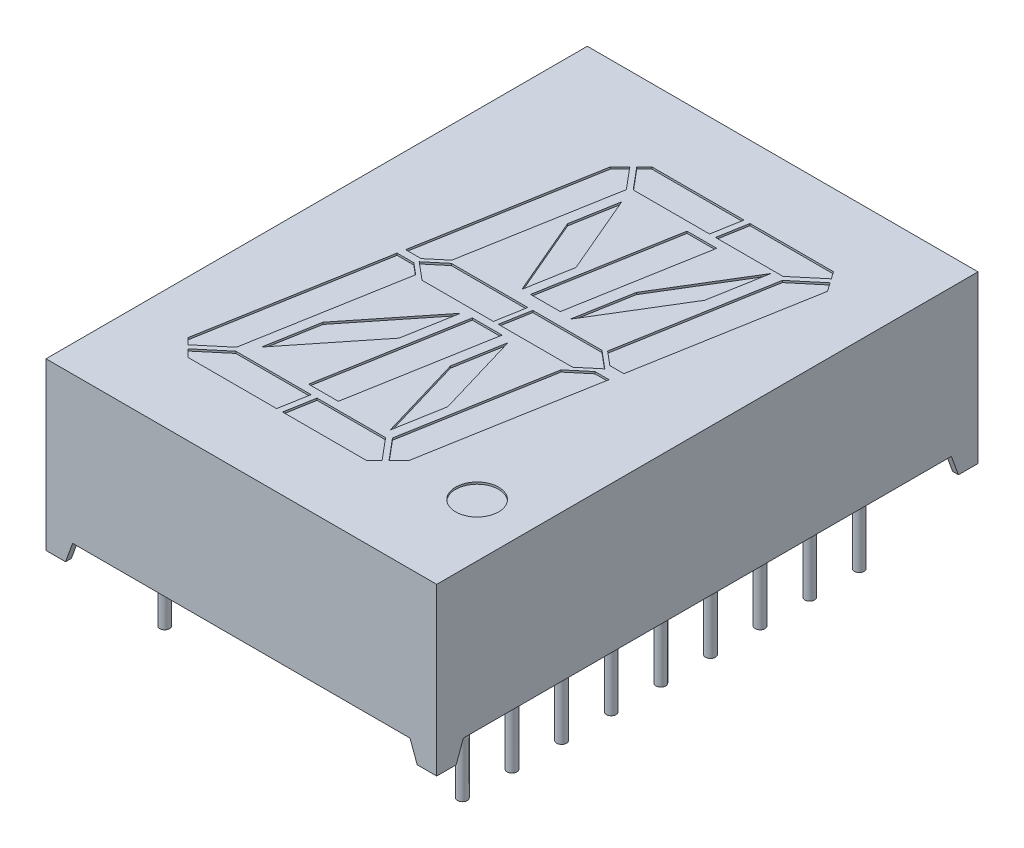
from build123d import *

# Parameters (mm, degrees)
SKETCH1_W          = 20
SKETCH1_H          = 27.71
EXTRUDE2_DEPTH     = 8.5
CUT_EXTRUDE2_DEPTH = 28.71
CUT_EXTRUDE3_DEPTH = 21
SKETCH6_R          = 1.1
CUT_EXTRUDE4_DEPTH = 0.1
SKETCH7_W          = 1.063970234
SKETCH7_H          = 1.063970234
CUT_EXTRUDE6_DEPTH = 1
SKETCH7_3_R        = 0.25
EXTRUDE3_DEPTH     = 1
SKETCH7_4_R        = 0.25
EXTRUDE4_DEPTH     = 4
SKETCH8_W          = 0.025316456
SKETCH8_H          = 0.026582278
CUT_EXTRUDE7_DEPTH = 0.01


with BuildPart() as part:
    # Sketch1 → Extrude2 (new body)
    with BuildSketch(Plane(origin=(0, 0, 0), x_dir=(1, 0, 0), z_dir=(0, 1, 0))):
        Rectangle(SKETCH1_W, SKETCH1_H)
    extrude(amount=-EXTRUDE2_DEPTH)

    # Sketch2 → Cut-Extrude2 (cut, through all)
    with BuildSketch(Plane.XY.offset(13.855)):
        Polygon((-9, -8.5), (-8.636029766, -7.5), (8.636029766, -7.5), (9, -8.5), align=None)
    extrude(amount=-CUT_EXTRUDE2_DEPTH, mode=Mode.SUBTRACT)

    # Sketch3 → Cut-Extrude3 (cut, through all)
    with BuildSketch(Plane(origin=(10, 0, 0), x_dir=(0, 0, -1), z_dir=(1, 0, 0))):
        Polygon((-12.855, -8.5), (-12.491029766, -7.5), (12.491029766, -7.5), (12.855, -8.5), align=None)
    extrude(amount=-CUT_EXTRUDE3_DEPTH, mode=Mode.SUBTRACT)

    # Sketch6 → Cut-Extrude4 (cut)
    with BuildSketch(Plane(origin=(0, 0, 0), x_dir=(-1, 0, 0), z_dir=(0, 1, 0))):
        Polygon((3.564962214, -9.596238766), (4.061861152, -9.099339828), (5.633410629, -0.186639852), (4.838716052, -0.186639852), (3.983777505, -0.904018471), (2.644523899, -8.499303098), align=None)
        Polygon((-1.716762292, -10.16), (3.00120098, -10.16), (3.387510261, -9.77369072), (2.453012788, -8.66), (-1.452271821, -8.66), align=None)
        Polygon((4.84221745, 0.183701829), (5.698711859, 0.183701829), (7.30194989, 9.276116524), (6.981177825, 9.596888588), (5.636403429, 8.468488889), (4.261493481, 0.670987097), align=None)
        Polygon((-6.295793119, -10.16), (-2.021390276, -10.16), (-1.756899805, -8.66), (-5.211216056, -8.66), (-6.555990451, -9.788399699), align=None)
        Polygon((3.856184806, -0.75), (4.75, 0), (3.856184806, 0.75), (0.205292288, 0.75), (-0.059198183, -0.75), align=None)
        Polygon((5.475706527, 8.66), (6.803725871, 9.774340542), (6.418066413, 10.16), (1.888384149, 10.16), (1.623893678, 8.66), align=None)
        Polygon((-7.012763665, -9.136059945), (-6.699932303, -9.582829431), (-5.371912958, -8.468488889), (-4.031092235, -0.864316698), (-4.733554655, -0.274880741), (-5.45029869, -0.274880741), align=None)
        Polygon((-3.856184806, -0.75), (-0.313054836, -0.75), (-0.048564365, 0.75), (-3.856184806, 0.75), (-4.75, 0), align=None)
        Polygon((-2.188522317, 8.66), (1.319265694, 8.66), (1.583756165, 10.16), (-2.736710509, 10.16), (-3.123019789, 9.77369072), align=None)
        Polygon((-3.797370681, 9.099339828), (-5.336480587, 0.370613801), (-4.619464437, 0.370613801), (-3.673358746, 1.164490737), (-2.380033428, 8.499303098), (-3.300471743, 9.596238766), align=None)
        Polygon((-2.27297919, -8.210157035), (-0.749839272, -8.210157035), (0.450916268, -1.40033397), (-1.07222365, -1.40033397), align=None)
        Polygon((-0.625673028, 1.132180455), (0.89746689, 1.132180455), (2.154174684, 8.25932452), (0.631034766, 8.25932452), align=None)
        Polygon((1.407680367, 1.228827124), (4.531194855, 5.145212023), (5.002967697, 7.820768764), (1.879453208, 3.904383864), align=None)
        Polygon((-2.409232885, 5.69968464), (-1.112825589, 1.314182511), (-0.67100747, 3.819857575), (-1.967414766, 8.205359704), align=None)
        Polygon((-2.167540747, -4.194861436), (-1.659236888, -1.312127006), (-4.267446218, -5.599560209), (-4.775750076, -8.48229464), align=None)
        Polygon((0.482024646, -3.756424015), (2.222968776, -7.839914095), (2.63841102, -5.48382405), (0.89746689, -1.40033397), align=None)
        with Locations(Location((-7.273660374, 9.06, 0), (0, 0, 90))):  # turned: the seam where the file's is
            Circle(SKETCH6_R)
    extrude(amount=-CUT_EXTRUDE4_DEPTH, mode=Mode.SUBTRACT)

    # Sketch7 → Cut-Extrude6 (cut)
    with BuildSketch(Plane.XZ.offset(8.5)):
        with Locations((-9.168014883, 13.023014883)):
            Rectangle(SKETCH7_W, SKETCH7_H)
        with Locations((-9.168014883, -13.023014883)):
            Rectangle(SKETCH7_W, SKETCH7_H)
        with Locations((9.168014883, -13.023014883)):
            Rectangle(SKETCH7_W, SKETCH7_H)
        with Locations((9.168014883, 13.023014883)):
            Rectangle(SKETCH7_W, SKETCH7_H)
    extrude(amount=-CUT_EXTRUDE6_DEPTH, mode=Mode.SUBTRACT)

    # Sketch7_3 → Extrude3 (add)
    with BuildSketch(Plane.XZ.offset(8.5)):
        with Locations(Location((-7.62, 10.16, 0), (0, 0, 270))):  # turned: the seam where the file's is
            Circle(SKETCH7_3_R)
        with Locations(Location((-7.62, 7.62, 0), (0, 0, 270))):  # turned: the seam where the file's is
            Circle(SKETCH7_3_R)
        with Locations(Location((-7.62, 5.08, 0), (0, 0, 270))):  # turned: the seam where the file's is
            Circle(SKETCH7_3_R)
        with Locations(Location((-7.62, 2.54, 0), (0, 0, 270))):  # turned: the seam where the file's is
            Circle(SKETCH7_3_R)
        with Locations(Location((-7.62, 0, 0), (0, 0, 270))):  # turned: the seam where the file's is
            Circle(SKETCH7_3_R)
        with Locations(Location((-7.62, -2.54, 0), (0, 0, 270))):  # turned: the seam where the file's is
            Circle(SKETCH7_3_R)
        with Locations(Location((-7.62, -5.08, 0), (0, 0, 270))):  # turned: the seam where the file's is
            Circle(SKETCH7_3_R)
        with Locations(Location((-7.62, -7.62, 0), (0, 0, 270))):  # turned: the seam where the file's is
            Circle(SKETCH7_3_R)
        with Locations(Location((-7.62, -10.16, 0), (0, 0, 270))):  # turned: the seam where the file's is
            Circle(SKETCH7_3_R)
        with Locations(Location((7.62, -10.16, 0), (0, 0, 270))):  # turned: the seam where the file's is
            Circle(SKETCH7_3_R)
        with Locations(Location((7.62, -7.62, 0), (0, 0, 270))):  # turned: the seam where the file's is
            Circle(SKETCH7_3_R)
        with Locations(Location((7.62, -5.08, 0), (0, 0, 270))):  # turned: the seam where the file's is
            Circle(SKETCH7_3_R)
        with Locations(Location((7.62, -2.54, 0), (0, 0, 270))):  # turned: the seam where the file's is
            Circle(SKETCH7_3_R)
        with Locations(Location((7.62, 0, 0), (0, 0, 270))):  # turned: the seam where the file's is
            Circle(SKETCH7_3_R)
        with Locations(Location((7.62, 2.54, 0), (0, 0, 270))):  # turned: the seam where the file's is
            Circle(SKETCH7_3_R)
        with Locations(Location((7.62, 5.08, 0), (0, 0, 270))):  # turned: the seam where the file's is
            Circle(SKETCH7_3_R)
        with Locations(Location((7.62, 7.62, 0), (0, 0, 270))):  # turned: the seam where the file's is
            Circle(SKETCH7_3_R)
        with Locations(Location((7.62, 10.16, 0), (0, 0, 270))):  # turned: the seam where the file's is
            Circle(SKETCH7_3_R)
    extrude(amount=-EXTRUDE3_DEPTH)

    # Sketch7_4 → Extrude4 (add)
    with BuildSketch(Plane.XZ.offset(8.5)):
        with Locations(Location((-7.62, 10.16, 0), (0, 0, 270))):  # turned: the seam where the file's is
            Circle(SKETCH7_4_R)
        with Locations(Location((-7.62, 7.62, 0), (0, 0, 270))):  # turned: the seam where the file's is
            Circle(SKETCH7_4_R)
        with Locations(Location((-7.62, 5.08, 0), (0, 0, 270))):  # turned: the seam where the file's is
            Circle(SKETCH7_4_R)
        with Locations(Location((-7.62, 2.54, 0), (0, 0, 270))):  # turned: the seam where the file's is
            Circle(SKETCH7_4_R)
        with Locations(Location((-7.62, 0, 0), (0, 0, 270))):  # turned: the seam where the file's is
            Circle(SKETCH7_4_R)
        with Locations(Location((-7.62, -2.54, 0), (0, 0, 270))):  # turned: the seam where the file's is
            Circle(SKETCH7_4_R)
        with Locations(Location((-7.62, -5.08, 0), (0, 0, 270))):  # turned: the seam where the file's is
            Circle(SKETCH7_4_R)
        with Locations(Location((-7.62, -7.62, 0), (0, 0, 270))):  # turned: the seam where the file's is
            Circle(SKETCH7_4_R)
        with Locations(Location((-7.62, -10.16, 0), (0, 0, 270))):  # turned: the seam where the file's is
            Circle(SKETCH7_4_R)
        with Locations(Location((7.62, -10.16, 0), (0, 0, 270))):  # turned: the seam where the file's is
            Circle(SKETCH7_4_R)
        with Locations(Location((7.62, -7.62, 0), (0, 0, 270))):  # turned: the seam where the file's is
            Circle(SKETCH7_4_R)
        with Locations(Location((7.62, -5.08, 0), (0, 0, 270))):  # turned: the seam where the file's is
            Circle(SKETCH7_4_R)
        with Locations(Location((7.62, -2.54, 0), (0, 0, 270))):  # turned: the seam where the file's is
            Circle(SKETCH7_4_R)
        with Locations(Location((7.62, 0, 0), (0, 0, 270))):  # turned: the seam where the file's is
            Circle(SKETCH7_4_R)
        with Locations(Location((7.62, 2.54, 0), (0, 0, 270))):  # turned: the seam where the file's is
            Circle(SKETCH7_4_R)
        with Locations(Location((7.62, 5.08, 0), (0, 0, 270))):  # turned: the seam where the file's is
            Circle(SKETCH7_4_R)
        with Locations(Location((7.62, 7.62, 0), (0, 0, 270))):  # turned: the seam where the file's is
            Circle(SKETCH7_4_R)
        with Locations(Location((7.62, 10.16, 0), (0, 0, 270))):  # turned: the seam where the file's is
            Circle(SKETCH7_4_R)
    extrude(amount=EXTRUDE4_DEPTH)

    # Sketch8 → Cut-Extrude7 (cut)
    with BuildSketch(Plane.XZ.offset(7.5)):
        Polygon((0.977729481, 10.289242078), (1.00118676, 10.363925622), (1.02592964, 10.363925622), (1.042345779, 10.313589388), (1.057871886, 10.363925622), (1.08360369, 10.363925622), (1.106843405, 10.289242078), (1.081665399, 10.289242078), (1.068670937, 10.340725464), (1.052254798, 10.289242078), (1.030755589, 10.289242078), (1.014438342, 10.340725464), (1.001621886, 10.289242078), align=None)
        Polygon((0.843552266, 10.289242078), (0.867009545, 10.363925622), (0.891752424, 10.363925622), (0.908168564, 10.313589388), (0.923694671, 10.363925622), (0.949426475, 10.363925622), (0.97266619, 10.289242078), (0.947488184, 10.289242078), (0.934493722, 10.340725464), (0.918077583, 10.289242078), (0.896578374, 10.289242078), (0.880261127, 10.340725464), (0.867444671, 10.289242078), align=None)
        Polygon((0.709375051, 10.289242078), (0.73283233, 10.363925622), (0.757575209, 10.363925622), (0.773991349, 10.313589388), (0.789517456, 10.363925622), (0.81524926, 10.363925622), (0.838488975, 10.289242078), (0.813310969, 10.289242078), (0.800316507, 10.340725464), (0.783900368, 10.289242078), (0.762401159, 10.289242078), (0.746083912, 10.340725464), (0.733267456, 10.289242078), align=None)
        with Locations((0.68152695, 10.350634483)):
            Rectangle(SKETCH8_W, SKETCH8_H)
        with BuildLine():
            add(Edge.make_bspline(
                [(0.565071254, 10.332754736), (0.565107782, 10.33397685), (0.565179511, 10.336376675), (0.565788673, 10.339884641), (0.566784197, 10.343207924), (0.568148535, 10.346370639), (0.569962523, 10.349326005), (0.572117537, 10.352144573), (0.574729451, 10.354728534), (0.577666487, 10.357167296), (0.580964415, 10.35934969), (0.584567036, 10.361249829), (0.588437356, 10.362874547), (0.592591377, 10.364206237), (0.597036955, 10.365197004), (0.601754731, 10.365920321), (0.60674808, 10.366393829), (0.610171668, 10.36643577), (0.611926475, 10.366457268)],
                knots=[0, 0, 0, 0, 0.907421153, 1.781872267, 2.635683434, 3.480115191, 4.332689235, 5.205575272, 6.109500117, 7.055808355, 8.037942167, 9.041423561, 10.07750834, 11.152467461, 12.277657752, 13.45734338, 14.696726425, 16, 16, 16, 16], degree=3))
            add(Edge.make_bspline(
                [(0.611926475, 10.366457268), (0.61394446, 10.366430003), (0.617852646, 10.366377199), (0.623520214, 10.365991826), (0.62878368, 10.365303877), (0.633681427, 10.364347296), (0.638285728, 10.363144011), (0.642719072, 10.361853367), (0.647000365, 10.360388787), (0.649773457, 10.35928865), (0.651147203, 10.35874366)],
                knots=[0, 0, 0, 0, 1.203182053, 2.33017619, 3.384818652, 4.366208123, 5.30340534, 6.221361684, 7.118890722, 8, 8, 8, 8], degree=3))
            Line((0.651147203, 10.35874366), (0.651147203, 10.334811698))
            Line((0.651147203, 10.334811698), (0.648299102, 10.334811698))
            add(Edge.make_bspline(
                [(0.648299102, 10.334811698), (0.646933538, 10.335892661), (0.644210429, 10.33804824), (0.639783471, 10.340816594), (0.635124459, 10.343189605), (0.630286065, 10.345172227), (0.625384697, 10.346747842), (0.620515629, 10.347874747), (0.615746646, 10.348614112), (0.612588325, 10.348695673), (0.611036443, 10.348735749)],
                knots=[0, 0, 0, 0, 1.030738938, 2.055426519, 3.085610749, 4.123842265, 5.148648843, 6.130724483, 7.081507926, 8, 8, 8, 8], degree=3))
            add(Edge.make_bspline(
                [(0.611036443, 10.348735749), (0.610607697, 10.348734448), (0.609689785, 10.348731664), (0.608220637, 10.348610349), (0.606564293, 10.348482504), (0.604783555, 10.34828639), (0.60299635, 10.348055246), (0.601336103, 10.347708778), (0.599835341, 10.347339627), (0.598928672, 10.346972361), (0.598496886, 10.346797458)],
                knots=[0, 0, 0, 0, 0.806537132, 1.726733348, 2.77251655, 3.932999672, 5.098049949, 6.161349231, 7.124375527, 8, 8, 8, 8], degree=3))
            add(Edge.make_bspline(
                [(0.598496886, 10.346797458), (0.5980174, 10.346569222), (0.597075108, 10.346120691), (0.595772577, 10.345306781), (0.594602092, 10.344412036), (0.59354139, 10.343450303), (0.592678994, 10.342287314), (0.592057833, 10.340888043), (0.591713263, 10.339238751), (0.591674191, 10.338063589), (0.591653532, 10.337442236)],
                knots=[0, 0, 0, 0, 1.02474257, 2.013837243, 2.958431669, 3.867978675, 4.769292696, 5.732237074, 6.800947934, 8, 8, 8, 8], degree=3))
            add(Edge.make_bspline(
                [(0.591653532, 10.337442236), (0.591684993, 10.33689637), (0.591746856, 10.335823036), (0.592328362, 10.334294607), (0.593212408, 10.332874471), (0.594491824, 10.331609134), (0.596105502, 10.330483022), (0.598036489, 10.329472259), (0.60031034, 10.328636502), (0.601947553, 10.328198629), (0.602808595, 10.327968344)],
                knots=[0, 0, 0, 0, 0.825427492, 1.623033598, 2.45033906, 3.348940377, 4.33183287, 5.428402891, 6.647546779, 8, 8, 8, 8], degree=3))
            add(Edge.make_bspline(
                [(0.602808595, 10.327968344), (0.604777836, 10.327523139), (0.608813048, 10.326610861), (0.614952861, 10.325423407), (0.621091563, 10.324197536), (0.62504782, 10.322983221), (0.626977899, 10.322390812)],
                knots=[0, 0, 0, 0, 0.976118991, 2.000185432, 3.024380873, 4, 4, 4, 4], degree=3))
            add(Edge.make_bspline(
                [(0.626977899, 10.322390812), (0.628016052, 10.322037089), (0.630036914, 10.321348535), (0.632936106, 10.320195887), (0.635579353, 10.318890752), (0.638036893, 10.317568714), (0.640229556, 10.316088657), (0.64222419, 10.314555897), (0.643976851, 10.312903093), (0.645503289, 10.3111536), (0.646846155, 10.309317239), (0.647999564, 10.307370097), (0.648960587, 10.305303648), (0.649783979, 10.30314825), (0.650395205, 10.300873715), (0.650817642, 10.298497298), (0.651115705, 10.296013812), (0.651136561, 10.294319476), (0.651147203, 10.293454894)],
                knots=[0, 0, 0, 0, 1.287376879, 2.505999703, 3.65855109, 4.746193839, 5.778582289, 6.760029101, 7.696159662, 8.601061861, 9.48181646, 10.363080883, 11.252765705, 12.153987336, 13.068239035, 14.012364187, 14.985753787, 16, 16, 16, 16], degree=3))
            add(Edge.make_bspline(
                [(0.651147203, 10.293454894), (0.651109903, 10.292298748), (0.651036496, 10.290023473), (0.650435046, 10.286694451), (0.649408535, 10.283545632), (0.648022176, 10.280542476), (0.646194683, 10.277728213), (0.64400256, 10.275050726), (0.64139225, 10.27255823), (0.638406923, 10.270259594), (0.635120075, 10.268180788), (0.63158607, 10.266344081), (0.627807219, 10.264837633), (0.623827334, 10.263556402), (0.619607941, 10.262604007), (0.615170971, 10.261884429), (0.610497108, 10.261471428), (0.607305697, 10.261420153), (0.605676475, 10.261393977)],
                knots=[0, 0, 0, 0, 0.894901293, 1.761149761, 2.608783409, 3.453876344, 4.314933854, 5.200038827, 6.12799933, 7.103249695, 8.113098521, 9.136064399, 10.182719798, 11.259667356, 12.370545059, 13.528828137, 14.738461593, 16, 16, 16, 16], degree=3))
            add(Edge.make_bspline(
                [(0.605676475, 10.261393977), (0.604007823, 10.261416369), (0.60067335, 10.261461117), (0.595691377, 10.261836087), (0.590733962, 10.262402588), (0.585862398, 10.263202042), (0.581179891, 10.264219698), (0.576763277, 10.265305656), (0.572684307, 10.266546046), (0.570110582, 10.267500091), (0.568868722, 10.267960432)],
                knots=[0, 0, 0, 0, 1.065379838, 2.128953261, 3.188461447, 4.250817766, 5.279613205, 6.247547721, 7.154416075, 8, 8, 8, 8], degree=3))
            Line((0.568868722, 10.267960432), (0.568868722, 10.290507901))
            Line((0.568868722, 10.290507901), (0.571697045, 10.290507901))
            add(Edge.make_bspline(
                [(0.571697045, 10.290507901), (0.572770004, 10.289707697), (0.574964235, 10.288071259), (0.578622987, 10.285985282), (0.582587048, 10.284035768), (0.586851949, 10.282313975), (0.59132449, 10.280893375), (0.595902036, 10.27986433), (0.600529101, 10.279225207), (0.603630692, 10.279152074), (0.605182013, 10.279115496)],
                knots=[0, 0, 0, 0, 0.89224925, 1.824673196, 2.804309561, 3.838364047, 4.890042674, 5.931526337, 6.965412421, 8, 8, 8, 8], degree=3))
            add(Edge.make_bspline(
                [(0.605182013, 10.279115496), (0.606277313, 10.279139706), (0.608467058, 10.279188106), (0.611741466, 10.27953736), (0.614976257, 10.280209102), (0.617019156, 10.281023438), (0.618038026, 10.281429578)],
                knots=[0, 0, 0, 0, 0.998993879, 1.997209027, 3.00113285, 4, 4, 4, 4], degree=3))
            add(Edge.make_bspline(
                [(0.618038026, 10.281429578), (0.618471505, 10.281631061), (0.619338174, 10.282033892), (0.620545178, 10.282806218), (0.621648481, 10.283735935), (0.622649487, 10.284788329), (0.623497543, 10.285957664), (0.624135203, 10.287227424), (0.624496022, 10.288589402), (0.624541859, 10.289523571), (0.624564924, 10.28999366)],
                knots=[0, 0, 0, 0, 1.005454979, 2.010239304, 3.005296729, 4.036100111, 5.060531193, 6.034954812, 7.011155677, 8, 8, 8, 8], degree=3))
            add(Edge.make_bspline(
                [(0.624564924, 10.28999366), (0.62453013, 10.290631591), (0.624463641, 10.291850619), (0.623863644, 10.293564316), (0.622865975, 10.295027427), (0.621712876, 10.296020421), (0.620595897, 10.29671918), (0.61955538, 10.29722442), (0.618355929, 10.297737843), (0.61697848, 10.29822704), (0.615443345, 10.298721087), (0.613734422, 10.299195756), (0.611851815, 10.299645316), (0.610535924, 10.299931468), (0.609849735, 10.300080686)],
                knots=[0, 0, 0, 0, 1.174343879, 2.244064321, 3.303704314, 4.407076671, 5.02483983, 5.732197225, 6.53898402, 7.431906431, 8.428480183, 9.514816237, 10.704066255, 12, 12, 12, 12], degree=3))
            add(Edge.make_bspline(
                [(0.609849735, 10.300080686), (0.60801711, 10.300457406), (0.604416407, 10.301197578), (0.599011332, 10.302291874), (0.593518278, 10.303604392), (0.589847728, 10.304733604), (0.587935178, 10.305321983)],
                knots=[0, 0, 0, 0, 0.995788186, 1.956503735, 2.935230479, 4, 4, 4, 4], degree=3))
            add(Edge.make_bspline(
                [(0.587935178, 10.305321983), (0.586988621, 10.305641224), (0.585137004, 10.306265712), (0.582496406, 10.307352031), (0.580049232, 10.308525888), (0.577782598, 10.309767857), (0.575707233, 10.31111029), (0.573820943, 10.312535624), (0.572122986, 10.314040406), (0.570634237, 10.315656126), (0.56930548, 10.317366474), (0.568193136, 10.319217087), (0.56719755, 10.321160616), (0.566444396, 10.32325406), (0.565819886, 10.325452587), (0.565398144, 10.327784522), (0.565103781, 10.330228739), (0.565082217, 10.331903339), (0.565071254, 10.332754736)],
                knots=[0, 0, 0, 0, 1.237326419, 2.420410185, 3.534642089, 4.598489486, 5.620241961, 6.59385002, 7.525152549, 8.426792174, 9.312230456, 10.203151844, 11.098070343, 12.012931196, 12.954244379, 13.926618287, 14.945853925, 16, 16, 16, 16], degree=3))
        make_face()
        with BuildLine():
            Line((0.47266619, 10.363925622), (0.496716823, 10.363925622))
            Line((0.496716823, 10.363925622), (0.496716823, 10.356093344))
            add(Edge.make_bspline(
                [(0.496716823, 10.356093344), (0.497810017, 10.356902139), (0.499917679, 10.358461483), (0.503092238, 10.360538545), (0.506110538, 10.362322967), (0.50904089, 10.363846085), (0.512047167, 10.365058255), (0.515285301, 10.365876636), (0.518786897, 10.36637936), (0.521213967, 10.366430721), (0.522468405, 10.366457268)],
                knots=[0, 0, 0, 0, 1.150945962, 2.219006967, 3.209666795, 4.118194914, 5.012574058, 5.946577101, 6.93868214, 8, 8, 8, 8], degree=3))
            add(Edge.make_bspline(
                [(0.522468405, 10.366457268), (0.52348468, 10.36643432), (0.525463661, 10.366389634), (0.528341961, 10.366047913), (0.531043927, 10.365499504), (0.533572764, 10.364731098), (0.535922464, 10.363728067), (0.538066144, 10.362456432), (0.540068721, 10.361023718), (0.541850668, 10.359317353), (0.543466214, 10.357419434), (0.544848785, 10.355287025), (0.54602649, 10.352954086), (0.54696759, 10.350402236), (0.547722678, 10.347643931), (0.548246611, 10.344664684), (0.548567203, 10.341477556), (0.548599143, 10.339282426), (0.548615557, 10.338154262)],
                knots=[0, 0, 0, 0, 1.108959949, 2.159465255, 3.158589008, 4.114545495, 5.039534357, 5.93921201, 6.830099133, 7.720870013, 8.624681761, 9.544731627, 10.487599671, 11.471264588, 12.508152322, 13.604835107, 14.769030043, 16, 16, 16, 16], degree=3))
            Line((0.548615557, 10.338154262), (0.548615557, 10.289242078))
            Line((0.548615557, 10.289242078), (0.524564924, 10.289242078))
            Line((0.524564924, 10.289242078), (0.524564924, 10.326821192))
            add(Edge.make_bspline(
                [(0.524564924, 10.326821192), (0.524563289, 10.327737663), (0.524560158, 10.329491879), (0.52447782, 10.331997685), (0.524356919, 10.334265858), (0.524218214, 10.336307886), (0.523965198, 10.338154637), (0.523587489, 10.339820798), (0.523116663, 10.3413404), (0.522652344, 10.342247101), (0.522428849, 10.342683534)],
                knots=[0, 0, 0, 0, 1.361401701, 2.605856924, 3.723918663, 4.735739235, 5.645738665, 6.489217889, 7.27279937, 8, 8, 8, 8], degree=3))
            add(Edge.make_bspline(
                [(0.522428849, 10.342683534), (0.52219884, 10.343082239), (0.521746663, 10.343866061), (0.520826399, 10.344872372), (0.519747556, 10.345716122), (0.518470353, 10.346374223), (0.516980786, 10.346864726), (0.515259927, 10.347245297), (0.513268185, 10.347417175), (0.511860717, 10.347451666), (0.511115557, 10.347469926)],
                knots=[0, 0, 0, 0, 0.849004071, 1.669068917, 2.503060811, 3.370079215, 4.310762265, 5.396376419, 6.621555549, 8, 8, 8, 8], degree=3))
            add(Edge.make_bspline(
                [(0.511115557, 10.347469926), (0.510574615, 10.347450087), (0.509463198, 10.347409326), (0.507745746, 10.347217785), (0.505956486, 10.346818626), (0.503437817, 10.346173681), (0.500272607, 10.344979827), (0.497913073, 10.34362668), (0.496716823, 10.342940654)],
                knots=[0, 0, 0, 0, 0.638062719, 1.310959128, 2.033463623, 2.796942592, 4.376095945, 6, 6, 6, 6], degree=3))
            Line((0.496716823, 10.342940654), (0.496716823, 10.289242078))
            Line((0.496716823, 10.289242078), (0.47266619, 10.289242078))
            Line((0.47266619, 10.289242078), (0.47266619, 10.363925622))
        make_face()
        with BuildLine():
            Line((0.375197836, 10.363925622), (0.399248469, 10.363925622))
            Line((0.399248469, 10.363925622), (0.399248469, 10.326346508))
            add(Edge.make_bspline(
                [(0.399248469, 10.326346508), (0.399273475, 10.324816519), (0.399323447, 10.321759028), (0.399599998, 10.317995933), (0.399984484, 10.315154394), (0.400352024, 10.313322805), (0.400783895, 10.311774689), (0.401196157, 10.310888927), (0.401384545, 10.310484167)],
                knots=[0, 0, 0, 0, 1.709111167, 3.415443484, 4.21113913, 4.910175115, 5.501990373, 6, 6, 6, 6], degree=3))
            add(Edge.make_bspline(
                [(0.401384545, 10.310484167), (0.401629006, 10.310086104), (0.402108305, 10.309305645), (0.403045656, 10.308292769), (0.40413944, 10.307463401), (0.405410616, 10.306783933), (0.406898725, 10.306304746), (0.408622642, 10.305951991), (0.410602827, 10.305741438), (0.412011655, 10.305712884), (0.412757171, 10.305697774)],
                knots=[0, 0, 0, 0, 0.860202684, 1.686548532, 2.528236983, 3.382486038, 4.33249885, 5.401154041, 6.624757403, 8, 8, 8, 8], degree=3))
            add(Edge.make_bspline(
                [(0.412757171, 10.305697774), (0.41388806, 10.305757875), (0.416195756, 10.305880516), (0.419071066, 10.306547182), (0.421388404, 10.307407147), (0.42324612, 10.308157582), (0.425153842, 10.309131683), (0.426433385, 10.309853124), (0.42709657, 10.310227046)],
                knots=[0, 0, 0, 0, 1.33818541, 2.730705359, 3.468371228, 4.262126284, 5.099261778, 6, 6, 6, 6], degree=3))
            Line((0.42709657, 10.310227046), (0.42709657, 10.363925622))
            Line((0.42709657, 10.363925622), (0.451147203, 10.363925622))
            Line((0.451147203, 10.363925622), (0.451147203, 10.289242078))
            Line((0.451147203, 10.289242078), (0.42709657, 10.289242078))
            Line((0.42709657, 10.289242078), (0.42709657, 10.297074356))
            add(Edge.make_bspline(
                [(0.42709657, 10.297074356), (0.426039163, 10.296268205), (0.423980859, 10.294698983), (0.420801621, 10.292658562), (0.417717723, 10.290859793), (0.414664713, 10.289346976), (0.411549758, 10.288140202), (0.408287, 10.287329213), (0.404870594, 10.28678541), (0.402533879, 10.286735716), (0.401344988, 10.286710432)],
                knots=[0, 0, 0, 0, 1.126119141, 2.192057864, 3.198061997, 4.149848529, 5.076251285, 6.021887753, 6.99356175, 8, 8, 8, 8], degree=3))
            add(Edge.make_bspline(
                [(0.401344988, 10.286710432), (0.400348723, 10.286735833), (0.398403836, 10.286785419), (0.395568987, 10.287094971), (0.39289788, 10.287646194), (0.390404496, 10.28844205), (0.38806881, 10.289433409), (0.385895138, 10.290637389), (0.383909289, 10.29210067), (0.382081137, 10.293760609), (0.380442037, 10.295651906), (0.379045127, 10.297781284), (0.377840765, 10.300118205), (0.3768915, 10.302680842), (0.376100176, 10.305447114), (0.375595412, 10.308445743), (0.375237759, 10.311655629), (0.37521141, 10.313871779), (0.375197836, 10.315013439)],
                knots=[0, 0, 0, 0, 1.08828964, 2.12453497, 3.110382522, 4.062402335, 4.978696626, 5.878225494, 6.769849763, 7.667011675, 8.57076823, 9.495541561, 10.442454184, 11.436213583, 12.475881554, 13.580560132, 14.753614518, 16, 16, 16, 16], degree=3))
            Line((0.375197836, 10.315013439), (0.375197836, 10.363925622))
        make_face()
        Polygon((0.280261127, 10.363925622), (0.352413026, 10.363925622), (0.352413026, 10.263925622), (0.32709657, 10.263925622), (0.32709657, 10.344938281), (0.280261127, 10.344938281), align=None)
        Polygon((0.192919355, 10.363925622), (0.265071254, 10.363925622), (0.265071254, 10.263925622), (0.192919355, 10.263925622), (0.192919355, 10.282912964), (0.239754798, 10.282912964), (0.239754798, 10.300634483), (0.196716823, 10.300634483), (0.196716823, 10.319621825), (0.239754798, 10.319621825), (0.239754798, 10.344938281), (0.192919355, 10.344938281), align=None)
        with BuildLine():
            add(Edge.make_bspline(
                [(0.076463659, 10.314024515), (0.076482974, 10.315172204), (0.076521226, 10.31744509), (0.076816417, 10.320809896), (0.077342443, 10.324075572), (0.078021624, 10.32725982), (0.07894413, 10.330338748), (0.080025844, 10.333346325), (0.08133549, 10.336251819), (0.082840342, 10.339053253), (0.084489814, 10.341725356), (0.086264563, 10.344245565), (0.088110343, 10.346628783), (0.090099655, 10.348823676), (0.092178837, 10.350865696), (0.094354365, 10.35275651), (0.09665943, 10.354459941), (0.098266592, 10.355482825), (0.099070462, 10.355994451)],
                knots=[0, 0, 0, 0, 1.105570398, 2.18947457, 3.250358341, 4.290584537, 5.323553275, 6.344225964, 7.367641686, 8.3905646, 9.405808457, 10.390761353, 11.358902336, 12.307789878, 13.241960776, 14.165076779, 15.082208636, 16, 16, 16, 16], degree=3))
            add(Edge.make_bspline(
                [(0.099070462, 10.355994451), (0.10030965, 10.356706773), (0.102794347, 10.358135049), (0.106778805, 10.359800889), (0.110900414, 10.361215112), (0.115259594, 10.362228552), (0.119898316, 10.362998387), (0.124903127, 10.363546558), (0.130310033, 10.363852061), (0.134045026, 10.363900543), (0.135977108, 10.363925622)],
                knots=[0, 0, 0, 0, 0.896321744, 1.797216976, 2.705381885, 3.628777036, 4.602292017, 5.655629376, 6.787275635, 8, 8, 8, 8], degree=3))
            Line((0.135977108, 10.363925622), (0.171400368, 10.363925622))
            Line((0.171400368, 10.363925622), (0.171400368, 10.263925622))
            Line((0.171400368, 10.263925622), (0.134968405, 10.263925622))
            add(Edge.make_bspline(
                [(0.134968405, 10.263925622), (0.132989709, 10.263942432), (0.12917305, 10.263974857), (0.123655733, 10.264389784), (0.118553395, 10.264995547), (0.113863815, 10.265889733), (0.109561365, 10.267004314), (0.105644074, 10.268392845), (0.102027841, 10.269885462), (0.099849305, 10.271160017), (0.098793564, 10.271777679)],
                knots=[0, 0, 0, 0, 1.267083275, 2.444046388, 3.541868212, 4.55639609, 5.499737919, 6.385160515, 7.217431253, 8, 8, 8, 8], degree=3))
            add(Edge.make_bspline(
                [(0.098793564, 10.271777679), (0.09794261, 10.27231422), (0.096250486, 10.273381133), (0.093849271, 10.275162986), (0.091619844, 10.277119063), (0.089491341, 10.279170881), (0.087511523, 10.281373768), (0.085668324, 10.283712475), (0.083964507, 10.286190569), (0.082406543, 10.288800039), (0.080985728, 10.291530091), (0.079796422, 10.294403149), (0.078747073, 10.297381679), (0.077941537, 10.300490642), (0.077243623, 10.303698478), (0.076808888, 10.307039822), (0.076522277, 10.31049231), (0.076483363, 10.3128372), (0.076463659, 10.314024515)],
                knots=[0, 0, 0, 0, 0.964065863, 1.917049184, 2.86229036, 3.805247319, 4.749389377, 5.698846072, 6.657678277, 7.629829384, 8.610569287, 9.604676042, 10.607940105, 11.6349849, 12.681042988, 13.752616828, 14.862056989, 16, 16, 16, 16], degree=3))
        make_face()
        with BuildLine():
            add(Edge.make_bspline(
                [(0.103045937, 10.313866287), (0.103089239, 10.312287857), (0.103172852, 10.309240057), (0.103878247, 10.304844413), (0.105017497, 10.300801463), (0.106355189, 10.297689047), (0.107692581, 10.29541573), (0.108820104, 10.293817459), (0.11006977, 10.292303259), (0.11146038, 10.290894419), (0.112995564, 10.289587383), (0.114656823, 10.288358473), (0.116456864, 10.287229827), (0.117729895, 10.286569821), (0.11837426, 10.286235749)],
                knots=[0, 0, 0, 0, 1.694683197, 3.272273219, 4.767406206, 6.197615014, 6.895990032, 7.597410435, 8.296503208, 9.002591366, 9.720792421, 10.460154445, 11.220583224, 12, 12, 12, 12], degree=3))
            add(Edge.make_bspline(
                [(0.11837426, 10.286235749), (0.119049195, 10.285929235), (0.120386963, 10.285321702), (0.122457239, 10.284587615), (0.12454994, 10.284025288), (0.126744168, 10.283552865), (0.129220927, 10.283275729), (0.132143419, 10.283063053), (0.135600092, 10.282926125), (0.138086687, 10.282917555), (0.139418564, 10.282912964)],
                knots=[0, 0, 0, 0, 0.826913061, 1.638999358, 2.447478739, 3.243919028, 4.140906711, 5.225381046, 6.513851968, 8, 8, 8, 8], degree=3))
            Line((0.139418564, 10.282912964), (0.146083912, 10.282912964))
            Line((0.146083912, 10.282912964), (0.146083912, 10.344938281))
            Line((0.146083912, 10.344938281), (0.139418564, 10.344938281))
            add(Edge.make_bspline(
                [(0.139418564, 10.344938281), (0.138660372, 10.344933235), (0.137196637, 10.344923494), (0.135080184, 10.344884391), (0.133115422, 10.344824075), (0.131308071, 10.344752232), (0.129651935, 10.344637329), (0.128164101, 10.344468732), (0.12682175, 10.344324345), (0.125254116, 10.344057225), (0.123400967, 10.34364077), (0.121239701, 10.342962678), (0.119099169, 10.342112259), (0.117710595, 10.341427295), (0.117009545, 10.341081477)],
                knots=[0, 0, 0, 0, 1.186775798, 2.291144404, 3.313233901, 4.263515562, 5.122260739, 5.910868134, 6.60717912, 7.234883681, 8.398964994, 9.577230746, 10.776813768, 12, 12, 12, 12], degree=3))
            add(Edge.make_bspline(
                [(0.117009545, 10.341081477), (0.116425831, 10.340738), (0.115277894, 10.340062517), (0.113633749, 10.338956654), (0.11214701, 10.337721654), (0.110740948, 10.336438556), (0.109488082, 10.335048102), (0.108314788, 10.333597623), (0.107304533, 10.332035229), (0.106059538, 10.3298417), (0.104839806, 10.32680833), (0.103799046, 10.322841787), (0.103162531, 10.318481777), (0.103085797, 10.315444195), (0.103045937, 10.313866287)],
                knots=[0, 0, 0, 0, 0.755109416, 1.485004392, 2.205961541, 2.908125208, 3.605307969, 4.290649036, 4.985852759, 5.676964147, 7.100721462, 8.614478074, 10.241350405, 12, 12, 12, 12], degree=3))
        make_face(mode=Mode.SUBTRACT)
        with Locations((0.044818089, 10.350634483)):
            Rectangle(SKETCH8_W, SKETCH8_H)
        with BuildLine():
            add(Edge.make_bspline(
                [(-0.029825898, 10.366457268), (-0.028235793, 10.366435442), (-0.025114671, 10.3663926), (-0.020543226, 10.365915898), (-0.016178423, 10.365197431), (-0.012030805, 10.364179259), (-0.008124243, 10.362822917), (-0.00444319, 10.361204903), (-0.001053828, 10.359187097), (0.001009902, 10.357610155), (0.002037235, 10.356825148)],
                knots=[0, 0, 0, 0, 1.123606455, 2.205459211, 3.245124445, 4.248821949, 5.220056174, 6.165006393, 7.086533249, 8, 8, 8, 8], degree=3))
            add(Edge.make_bspline(
                [(0.002037235, 10.356825148), (0.002988982, 10.355970373), (0.004888797, 10.354264131), (0.00735473, 10.351292704), (0.009477815, 10.34800966), (0.011263368, 10.344407437), (0.012694292, 10.340490708), (0.013717425, 10.336246046), (0.014336671, 10.331685266), (0.014403836, 10.328537332), (0.014438342, 10.326920084)],
                knots=[0, 0, 0, 0, 0.916457077, 1.82937027, 2.759194969, 3.714948755, 4.706655623, 5.743329475, 6.840637961, 8, 8, 8, 8], degree=3))
            add(Edge.make_bspline(
                [(0.014438342, 10.326920084), (0.014399582, 10.325216857), (0.014324459, 10.321915777), (0.013660699, 10.31714359), (0.012591087, 10.312725909), (0.011053529, 10.308674001), (0.009123087, 10.304980809), (0.006858594, 10.301608974), (0.004238068, 10.29856605), (0.00223093, 10.296820611), (0.001226317, 10.295946983)],
                knots=[0, 0, 0, 0, 1.171797512, 2.271099083, 3.308930235, 4.294129479, 5.24602549, 6.17106565, 7.084581485, 8, 8, 8, 8], degree=3))
            add(Edge.make_bspline(
                [(0.001226317, 10.295946983), (0.000200403, 10.295178522), (-0.001863815, 10.293632317), (-0.00526666, 10.291729707), (-0.00889435, 10.290141513), (-0.012716085, 10.288864793), (-0.016691071, 10.287910176), (-0.020754625, 10.28721751), (-0.024898426, 10.286788828), (-0.027688807, 10.28673669), (-0.029094095, 10.286710432)],
                knots=[0, 0, 0, 0, 0.952046378, 1.915591786, 2.889970712, 3.892742799, 4.906722985, 5.925995921, 6.955492795, 8, 8, 8, 8], degree=3))
            add(Edge.make_bspline(
                [(-0.029094095, 10.286710432), (-0.030340899, 10.28672683), (-0.032792539, 10.286759073), (-0.036391379, 10.287089676), (-0.039849338, 10.287591614), (-0.043156256, 10.288330186), (-0.046323253, 10.289251803), (-0.049377392, 10.290283865), (-0.052336625, 10.291419096), (-0.054237269, 10.292303373), (-0.055181911, 10.292742869)],
                knots=[0, 0, 0, 0, 1.107549047, 2.177816721, 3.208424937, 4.210433793, 5.185680559, 6.13785309, 7.074491882, 8, 8, 8, 8], degree=3))
            Line((-0.055181911, 10.292742869), (-0.055181911, 10.313292711))
            Line((-0.055181911, 10.313292711), (-0.051839348, 10.313292711))
            add(Edge.make_bspline(
                [(-0.051839348, 10.313292711), (-0.05133877, 10.312876825), (-0.050253745, 10.311975372), (-0.048486914, 10.310528785), (-0.046316594, 10.309028495), (-0.044669564, 10.30813387), (-0.043789506, 10.307655844)],
                knots=[0, 0, 0, 0, 0.792743043, 1.718305972, 2.780820752, 4, 4, 4, 4], degree=3))
            add(Edge.make_bspline(
                [(-0.043789506, 10.307655844), (-0.042860571, 10.307217205), (-0.040954662, 10.306317245), (-0.038411454, 10.305439857), (-0.036208274, 10.304914488), (-0.034394614, 10.304648923), (-0.032460317, 10.304462064), (-0.031125171, 10.304442173), (-0.030439031, 10.304431951)],
                knots=[0, 0, 0, 0, 1.332360773, 2.733622135, 3.480580446, 4.268165618, 5.10999921, 6, 6, 6, 6], degree=3))
            add(Edge.make_bspline(
                [(-0.030439031, 10.304431951), (-0.029673392, 10.304451282), (-0.02818962, 10.304488744), (-0.026029252, 10.304768792), (-0.024004635, 10.305236884), (-0.022116597, 10.305914828), (-0.020362766, 10.306766595), (-0.018742742, 10.30780804), (-0.01724931, 10.309031312), (-0.015930368, 10.310472944), (-0.014737554, 10.312052684), (-0.013718377, 10.313786851), (-0.012805914, 10.315633436), (-0.012110978, 10.317637888), (-0.011551239, 10.319766663), (-0.01116231, 10.322029784), (-0.010920351, 10.324429294), (-0.010892434, 10.326075601), (-0.010878114, 10.326920084)],
                knots=[0, 0, 0, 0, 1.087372478, 2.107277257, 3.088614887, 4.033572876, 4.950837204, 5.852283781, 6.763600506, 7.684681617, 8.621202104, 9.570420019, 10.537986648, 11.542161979, 12.577980734, 13.661919757, 14.800668594, 16, 16, 16, 16], degree=3))
            add(Edge.make_bspline(
                [(-0.010878114, 10.326920084), (-0.010892888, 10.327784241), (-0.010921594, 10.329463253), (-0.011155108, 10.331904864), (-0.011570999, 10.334186296), (-0.012142247, 10.336311615), (-0.012866595, 10.338277634), (-0.013771712, 10.34007503), (-0.014808069, 10.341731838), (-0.016052627, 10.34319445), (-0.017416511, 10.344510771), (-0.018931402, 10.345646906), (-0.020590642, 10.34659505), (-0.022372822, 10.347399514), (-0.024305863, 10.347977912), (-0.026362399, 10.348414604), (-0.028551954, 10.34870316), (-0.030062308, 10.348724723), (-0.030834601, 10.348735749)],
                knots=[0, 0, 0, 0, 1.230336593, 2.390482092, 3.487897344, 4.52859895, 5.520747884, 6.465347575, 7.38981449, 8.296085817, 9.192433006, 10.084246191, 10.984321635, 11.908883871, 12.862027947, 13.850751296, 14.901019963, 16, 16, 16, 16], degree=3))
            add(Edge.make_bspline(
                [(-0.030834601, 10.348735749), (-0.031560366, 10.348726999), (-0.032975217, 10.348709942), (-0.035042218, 10.348500388), (-0.036999723, 10.348193617), (-0.038832865, 10.347753663), (-0.040535597, 10.347241112), (-0.042091931, 10.346668168), (-0.043504907, 10.346065041), (-0.044366197, 10.345597286), (-0.04477843, 10.345373407)],
                knots=[0, 0, 0, 0, 1.201052708, 2.34140671, 3.435973211, 4.479046096, 5.459661032, 6.378175262, 7.223757638, 8, 8, 8, 8], degree=3))
            add(Edge.make_bspline(
                [(-0.04477843, 10.345373407), (-0.045478636, 10.344943513), (-0.046833202, 10.344111871), (-0.04867193, 10.342710305), (-0.050316799, 10.341296045), (-0.051341311, 10.340339827), (-0.051839348, 10.339874989)],
                knots=[0, 0, 0, 0, 1.098601379, 2.125273733, 3.088655601, 4, 4, 4, 4], degree=3))
            Line((-0.051839348, 10.339874989), (-0.055181911, 10.339874989))
            Line((-0.055181911, 10.339874989), (-0.055181911, 10.360583059))
            add(Edge.make_bspline(
                [(-0.055181911, 10.360583059), (-0.054236521, 10.361020553), (-0.052345514, 10.361895647), (-0.049430935, 10.363049519), (-0.046442962, 10.364017679), (-0.043394589, 10.36492076), (-0.040222506, 10.365609121), (-0.036899476, 10.366102245), (-0.033417977, 10.366403157), (-0.031039588, 10.366438985), (-0.029825898, 10.366457268)],
                knots=[0, 0, 0, 0, 0.952012952, 1.904254716, 2.862729541, 3.822037426, 4.808956931, 5.82647221, 6.890850784, 8, 8, 8, 8], degree=3))
        make_face()
        with BuildLine():
            add(Edge.make_bspline(
                [(-0.147586974, 10.326623407), (-0.147562279, 10.328128313), (-0.147514141, 10.331061779), (-0.146974824, 10.33533357), (-0.146162044, 10.339369568), (-0.144989513, 10.343156776), (-0.14350912, 10.346714051), (-0.141658181, 10.350003843), (-0.139487177, 10.353057073), (-0.13699614, 10.355846958), (-0.134194937, 10.358345468), (-0.131120755, 10.360540721), (-0.127746928, 10.362354163), (-0.124132617, 10.363866254), (-0.120247965, 10.365035489), (-0.116093746, 10.365848206), (-0.111676612, 10.366383676), (-0.108638193, 10.366432328), (-0.107080645, 10.366457268)],
                knots=[0, 0, 0, 0, 1.120167703, 2.183507516, 3.201345984, 4.182878364, 5.131270247, 6.065524964, 6.98789854, 7.91635504, 8.84481154, 9.778033504, 10.722808862, 11.691211189, 12.691525459, 13.738229926, 14.840575679, 16, 16, 16, 16], degree=3))
            add(Edge.make_bspline(
                [(-0.107080645, 10.366457268), (-0.105523124, 10.366432246), (-0.102484758, 10.366383434), (-0.098067249, 10.365849102), (-0.093908154, 10.365031152), (-0.090018847, 10.363875051), (-0.086410101, 10.362348501), (-0.083040235, 10.360541453), (-0.079966469, 10.35834526), (-0.077164984, 10.355847068), (-0.074674665, 10.353056842), (-0.072501074, 10.350004659), (-0.07065866, 10.346708705), (-0.069140807, 10.343165659), (-0.068007482, 10.339364822), (-0.067184019, 10.33533438), (-0.066647811, 10.33106156), (-0.066599236, 10.328128239), (-0.066574316, 10.326623407)],
                knots=[0, 0, 0, 0, 1.15937715, 2.261678054, 3.308339936, 4.313313916, 5.277148057, 6.221884977, 7.155068972, 8.083487698, 9.011906424, 9.934242473, 10.868459181, 11.818729666, 12.798784262, 13.81658132, 14.879877871, 16, 16, 16, 16], degree=3))
            add(Edge.make_bspline(
                [(-0.066574316, 10.326623407), (-0.066599418, 10.325111974), (-0.066648461, 10.322158946), (-0.067184128, 10.317860199), (-0.068001091, 10.313799103), (-0.069166622, 10.309986552), (-0.0706729, 10.306424076), (-0.072519845, 10.303117887), (-0.0747156, 10.300071114), (-0.077225035, 10.297280949), (-0.080037801, 10.294786421), (-0.083125299, 10.292608316), (-0.086488839, 10.290799523), (-0.090089192, 10.289271758), (-0.093976853, 10.288139212), (-0.09811348, 10.287321057), (-0.102510962, 10.286783147), (-0.105529688, 10.286735112), (-0.107080645, 10.286710432)],
                knots=[0, 0, 0, 0, 1.123883205, 2.195836198, 3.217400301, 4.202580581, 5.156396106, 6.089661422, 7.013912723, 7.944661364, 8.875797629, 9.805201257, 10.748976071, 11.711828658, 12.709674189, 13.755270167, 14.846705509, 16, 16, 16, 16], degree=3))
            add(Edge.make_bspline(
                [(-0.107080645, 10.286710432), (-0.108651383, 10.286735154), (-0.111709547, 10.286783287), (-0.116152959, 10.28731949), (-0.120326798, 10.288132495), (-0.124225423, 10.289298891), (-0.127851174, 10.290810305), (-0.131211249, 10.292644962), (-0.134282556, 10.29484702), (-0.13706981, 10.297354176), (-0.139550051, 10.300159578), (-0.141718968, 10.303209201), (-0.143526185, 10.306528918), (-0.145007956, 10.310083786), (-0.146180128, 10.313877555), (-0.147001113, 10.317911661), (-0.147507104, 10.322186657), (-0.147559888, 10.325118788), (-0.147586974, 10.326623407)],
                knots=[0, 0, 0, 0, 1.167358552, 2.272800965, 3.322628764, 4.326027541, 5.29287265, 6.238482395, 7.166210353, 8.096447471, 9.020151799, 9.945039072, 10.873038967, 11.824425184, 12.804379233, 13.820580988, 14.881633558, 16, 16, 16, 16], degree=3))
        make_face()
        with BuildLine():
            add(Edge.make_bspline(
                [(-0.117879696, 10.345116287), (-0.118234699, 10.344616206), (-0.118957172, 10.343598481), (-0.11983298, 10.341893827), (-0.120611558, 10.340061375), (-0.121232031, 10.338033748), (-0.121715876, 10.335738634), (-0.122024331, 10.333091079), (-0.122254674, 10.330055686), (-0.122265029, 10.327902955), (-0.122270519, 10.326761856)],
                knots=[0, 0, 0, 0, 0.765001119, 1.556867793, 2.387180485, 3.249178546, 4.200309879, 5.312433676, 6.575401142, 8, 8, 8, 8], degree=3))
            add(Edge.make_bspline(
                [(-0.122270519, 10.326761856), (-0.122252785, 10.325686983), (-0.122218809, 10.323627641), (-0.122033025, 10.320667777), (-0.121681565, 10.317978279), (-0.121188048, 10.315553571), (-0.120580458, 10.313381501), (-0.119845656, 10.311449172), (-0.119012219, 10.309735217), (-0.118326464, 10.308730096), (-0.117998367, 10.308249198)],
                knots=[0, 0, 0, 0, 1.337015307, 2.56157572, 3.686511827, 4.707709802, 5.636963675, 6.488272502, 7.276717686, 8, 8, 8, 8], degree=3))
            add(Edge.make_bspline(
                [(-0.117998367, 10.308249198), (-0.117660979, 10.307810108), (-0.116999114, 10.306948728), (-0.115824324, 10.30586384), (-0.114552804, 10.304973579), (-0.113188343, 10.304277595), (-0.111728153, 10.303795876), (-0.110225792, 10.303439387), (-0.10866961, 10.303213984), (-0.107615415, 10.303182234), (-0.107080645, 10.303166129)],
                knots=[0, 0, 0, 0, 1.058488312, 2.076474566, 3.046302828, 4.022760093, 4.996603884, 5.982315336, 6.976474174, 8, 8, 8, 8], degree=3))
            add(Edge.make_bspline(
                [(-0.107080645, 10.303166129), (-0.106552713, 10.303177075), (-0.105520096, 10.303198485), (-0.10401743, 10.303378167), (-0.102606482, 10.303672757), (-0.101266608, 10.30409069), (-0.099974634, 10.304686173), (-0.09874029, 10.305542598), (-0.097524353, 10.306617929), (-0.096786105, 10.307468447), (-0.096400265, 10.307912964)],
                knots=[0, 0, 0, 0, 1.041978199, 2.038073998, 2.982578265, 3.884042198, 4.804014415, 5.778706634, 6.839057036, 8, 8, 8, 8], degree=3))
            add(Edge.make_bspline(
                [(-0.096400265, 10.307912964), (-0.09606678, 10.30838759), (-0.095365137, 10.309386191), (-0.094482161, 10.311090711), (-0.093750808, 10.313052631), (-0.093058568, 10.315236372), (-0.092540303, 10.317707521), (-0.092139565, 10.320460799), (-0.09193885, 10.323515225), (-0.091907275, 10.325647443), (-0.091890772, 10.326761856)],
                knots=[0, 0, 0, 0, 0.706185926, 1.485796665, 2.33004681, 3.254820698, 4.274138656, 5.402098861, 6.642194297, 8, 8, 8, 8], degree=3))
            add(Edge.make_bspline(
                [(-0.091890772, 10.326761856), (-0.091899928, 10.327764316), (-0.091917657, 10.329705421), (-0.092116442, 10.332511858), (-0.092445559, 10.335115613), (-0.092920721, 10.337506243), (-0.093501474, 10.339695127), (-0.094233563, 10.341653334), (-0.09507305, 10.343401053), (-0.095768258, 10.344424734), (-0.096103588, 10.344918502)],
                knots=[0, 0, 0, 0, 1.27086383, 2.460826804, 3.565079772, 4.596261907, 5.549370831, 6.432852304, 7.244093885, 8, 8, 8, 8], degree=3))
            add(Edge.make_bspline(
                [(-0.096103588, 10.344918502), (-0.096444078, 10.345335117), (-0.097115376, 10.3461565), (-0.098265308, 10.347238658), (-0.099542741, 10.348105152), (-0.100904819, 10.348809301), (-0.102363552, 10.349336974), (-0.103909994, 10.349744217), (-0.10556526, 10.349951798), (-0.106697783, 10.349984702), (-0.10727843, 10.350001572)],
                knots=[0, 0, 0, 0, 1.011466313, 1.994169768, 2.957274081, 3.905656451, 4.870834188, 5.869371193, 6.907620549, 8, 8, 8, 8], degree=3))
            add(Edge.make_bspline(
                [(-0.10727843, 10.350001572), (-0.108279839, 10.349949923), (-0.110279975, 10.349846763), (-0.112691124, 10.349109955), (-0.114492814, 10.348257899), (-0.115744805, 10.347403438), (-0.116893743, 10.346360006), (-0.11754783, 10.345534915), (-0.117879696, 10.345116287)],
                knots=[0, 0, 0, 0, 1.484683483, 2.96539121, 3.705388955, 4.438554905, 5.207767564, 6, 6, 6, 6], degree=3))
        make_face(mode=Mode.SUBTRACT)
        with BuildLine():
            Line((-0.238726215, 10.310227046), (-0.238726215, 10.363925622))
            Line((-0.238726215, 10.363925622), (-0.214675582, 10.363925622))
            Line((-0.214675582, 10.363925622), (-0.214675582, 10.32606961))
            add(Edge.make_bspline(
                [(-0.214675582, 10.32606961), (-0.214670115, 10.325179575), (-0.214659627, 10.323471944), (-0.214626604, 10.32101233), (-0.214546332, 10.318763726), (-0.214438793, 10.316717527), (-0.214251848, 10.314858061), (-0.213940509, 10.313183226), (-0.213519012, 10.3116777), (-0.213110662, 10.310776753), (-0.212915297, 10.310345717)],
                knots=[0, 0, 0, 0, 1.339742217, 2.570446543, 3.702449567, 4.726327994, 5.654556215, 6.512888379, 7.288529137, 8, 8, 8, 8], degree=3))
            add(Edge.make_bspline(
                [(-0.212915297, 10.310345717), (-0.21270529, 10.309960507), (-0.212289004, 10.309196925), (-0.211422148, 10.308226775), (-0.210406831, 10.30742274), (-0.209243155, 10.306747169), (-0.207848136, 10.306287123), (-0.206240137, 10.305925977), (-0.204374705, 10.305749493), (-0.203052655, 10.305715663), (-0.202353588, 10.305697774)],
                knots=[0, 0, 0, 0, 0.859137151, 1.703023591, 2.531884144, 3.395689496, 4.329139829, 5.403231912, 6.626892925, 8, 8, 8, 8], degree=3))
            add(Edge.make_bspline(
                [(-0.202353588, 10.305697774), (-0.201766149, 10.305720801), (-0.200585973, 10.305767061), (-0.198831409, 10.306016464), (-0.197105473, 10.306486696), (-0.194887172, 10.307331033), (-0.192285447, 10.308568325), (-0.190309066, 10.309688593), (-0.189359126, 10.310227046)],
                knots=[0, 0, 0, 0, 0.759272211, 1.52539342, 2.28366165, 3.065252147, 4.589423829, 6, 6, 6, 6], degree=3))
            Line((-0.189359126, 10.310227046), (-0.189359126, 10.363925622))
            Line((-0.189359126, 10.363925622), (-0.165308493, 10.363925622))
            Line((-0.165308493, 10.363925622), (-0.165308493, 10.289242078))
            Line((-0.165308493, 10.289242078), (-0.189359126, 10.289242078))
            Line((-0.189359126, 10.289242078), (-0.189359126, 10.297074356))
            add(Edge.make_bspline(
                [(-0.189359126, 10.297074356), (-0.190379865, 10.296292394), (-0.192361727, 10.29477414), (-0.195382591, 10.29273287), (-0.198326865, 10.29094493), (-0.201229034, 10.289411785), (-0.204184381, 10.288185389), (-0.207273481, 10.287341879), (-0.21051704, 10.28681158), (-0.212735211, 10.286744559), (-0.213864664, 10.286710432)],
                knots=[0, 0, 0, 0, 1.13602934, 2.205708752, 3.219814904, 4.178719654, 5.103700513, 6.040802208, 7.002410817, 8, 8, 8, 8], degree=3))
            add(Edge.make_bspline(
                [(-0.213864664, 10.286710432), (-0.215067813, 10.286742356), (-0.217419284, 10.286804748), (-0.220832529, 10.287471514), (-0.224040804, 10.288484351), (-0.22701537, 10.289941397), (-0.229718552, 10.291805371), (-0.23211767, 10.294077235), (-0.234230731, 10.296725338), (-0.235321065, 10.298736654), (-0.235878114, 10.29976423)],
                knots=[0, 0, 0, 0, 1.06596181, 2.083348439, 3.072786094, 4.043114605, 5.009947443, 5.973893017, 6.964867644, 8, 8, 8, 8], degree=3))
            add(Edge.make_bspline(
                [(-0.235878114, 10.29976423), (-0.2370602, 10.298787271), (-0.239363858, 10.296883365), (-0.242917452, 10.29434067), (-0.246396609, 10.292086369), (-0.249836861, 10.290176656), (-0.253232512, 10.288631768), (-0.256611639, 10.287526167), (-0.25996042, 10.286842721), (-0.26219368, 10.28675402), (-0.263291088, 10.286710432)],
                knots=[0, 0, 0, 0, 1.188124574, 2.315425566, 3.384037189, 4.39937427, 5.362203716, 6.270239573, 7.150007311, 8, 8, 8, 8], degree=3))
            add(Edge.make_bspline(
                [(-0.263291088, 10.286710432), (-0.26427434, 10.286733818), (-0.266187485, 10.28677932), (-0.268970022, 10.287114463), (-0.271566277, 10.287685742), (-0.273990004, 10.288478108), (-0.276225944, 10.289506823), (-0.278289073, 10.290754002), (-0.280137155, 10.2922645), (-0.28182994, 10.293963191), (-0.283319084, 10.295899859), (-0.284603722, 10.298037907), (-0.285674593, 10.300384694), (-0.286563935, 10.302919391), (-0.287252082, 10.305660796), (-0.287741418, 10.308603949), (-0.28803984, 10.311743811), (-0.288075181, 10.313905169), (-0.288093303, 10.315013439)],
                knots=[0, 0, 0, 0, 1.099136554, 2.138625863, 3.127574945, 4.066908717, 4.983764051, 5.873707737, 6.754323387, 7.645578618, 8.549333854, 9.478432518, 10.428234329, 11.428300305, 12.477672891, 13.584002437, 14.761160362, 16, 16, 16, 16], degree=3))
            Line((-0.288093303, 10.315013439), (-0.288093303, 10.363925622))
            Line((-0.288093303, 10.363925622), (-0.26404267, 10.363925622))
            Line((-0.26404267, 10.363925622), (-0.26404267, 10.32606961))
            add(Edge.make_bspline(
                [(-0.26404267, 10.32606961), (-0.264036997, 10.325172991), (-0.264026109, 10.323452192), (-0.263995861, 10.320979275), (-0.263907314, 10.318724798), (-0.263825593, 10.316678446), (-0.26365971, 10.31483241), (-0.263367742, 10.313168264), (-0.262940561, 10.311682329), (-0.26254853, 10.310777429), (-0.2623615, 10.310345717)],
                knots=[0, 0, 0, 0, 1.350818449, 2.592504867, 3.725474742, 4.749698069, 5.67770978, 6.515438232, 7.29174147, 8, 8, 8, 8], degree=3))
            add(Edge.make_bspline(
                [(-0.2623615, 10.310345717), (-0.262158044, 10.309960864), (-0.261755232, 10.309198909), (-0.260907257, 10.308221703), (-0.259888573, 10.307417645), (-0.258707859, 10.306748085), (-0.257288181, 10.306284048), (-0.255658911, 10.305930642), (-0.25376843, 10.305747087), (-0.252433018, 10.305714928), (-0.251720677, 10.305697774)],
                knots=[0, 0, 0, 0, 0.846272708, 1.675499002, 2.498229298, 3.366836971, 4.305509618, 5.396757786, 6.611368595, 8, 8, 8, 8], degree=3))
            add(Edge.make_bspline(
                [(-0.251720677, 10.305697774), (-0.250719557, 10.305744704), (-0.248705748, 10.305839105), (-0.246224246, 10.306559811), (-0.244195553, 10.307366348), (-0.242511951, 10.308179566), (-0.240653233, 10.309113502), (-0.239388401, 10.309844396), (-0.238726215, 10.310227046)],
                knots=[0, 0, 0, 0, 1.291206289, 2.597335145, 3.312416795, 4.112753053, 5.011956018, 6, 6, 6, 6], degree=3))
        make_face()
    extrude(amount=-CUT_EXTRUDE7_DEPTH, mode=Mode.SUBTRACT)


solid = part.part
